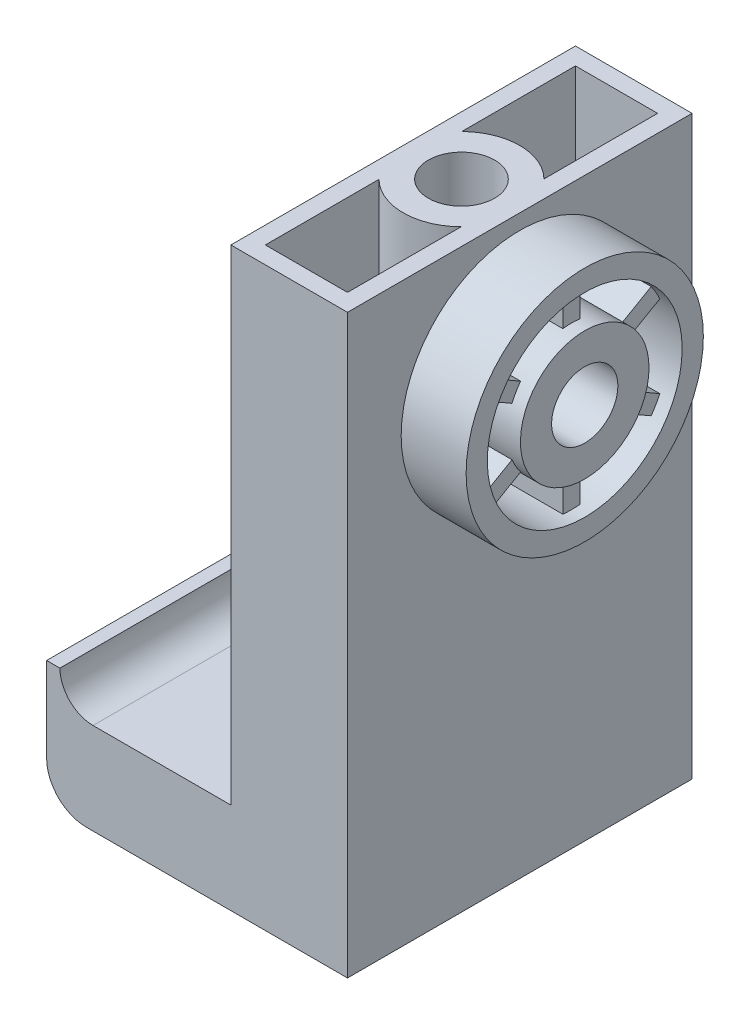
from build123d import *

# Parameters (mm, degrees)
BOSS_EXTRUDE1_DEPTH = 16.51
SKETCH2_R           = 11.3665
SKETCH2_R_2         = 3.175
BOSS_EXTRUDE2_DEPTH = 6.223
SKETCH3_W           = 1.27
SKETCH3_H           = 3.175
SKETCH4_R           = 3.175
CUT_EXTRUDE1_DEPTH  = 54.61


with BuildPart() as part:
    # Sketch1 → Boss-Extrude1 (new body, symmetric)
    with BuildSketch(Plane.XY):
        with BuildLine():
            Line((-28.829, 11.938), (-27.559, 11.938))
            ThreePointArc((-27.559, 11.938), (-26.62906403, 9.69293597), (-24.384, 8.763))
            Line((-24.384, 8.763), (-11.176, 8.763))
            Line((-11.176, 8.763), (-11.176, 55.245))
            Line((-11.176, 55.245), (0, 55.245))
            Line((0, 55.245), (0, 0))
            Line((0, 0), (-25.019, 0))
            ThreePointArc((-25.019, 0), (-27.713076836, 1.115923164), (-28.829, 3.81))
            Line((-28.829, 3.81), (-28.829, 11.938))
        make_face()
    extrude(amount=BOSS_EXTRUDE1_DEPTH, both=True)

    # Sketch2 → Boss-Extrude2 (add)
    with BuildSketch(Plane(origin=(0, 0, 0), x_dir=(0, 0, -1), z_dir=(1, 0, 0))):
        with Locations((0, 42.418)):
            Circle(SKETCH2_R)
        with Locations((0, 42.418)):
            Circle(SKETCH2_R_2, mode=Mode.SUBTRACT)
        with BuildLine():
            Line((-0.8255, 48.521932339), (-0.8255, 51.715926651))
            ThreePointArc((-0.8255, 51.715926651), (-4.66725, 50.501914132), (-7.639490682, 47.781867296))
            Line((-7.639490682, 47.781867296), (-4.873410469, 46.18487014))
            ThreePointArc((-4.873410469, 46.18487014), (-3.07975, 47.752283475), (-0.8255, 48.521932339))
        make_face(mode=Mode.SUBTRACT)
        with BuildLine():
            Line((0.8255, 48.521932339), (0.8255, 51.715926651))
            ThreePointArc((0.8255, 51.715926651), (4.66725, 50.501914132), (7.639490682, 47.781867296))
            Line((7.639490682, 47.781867296), (4.873410469, 46.18487014))
            ThreePointArc((4.873410469, 46.18487014), (3.07975, 47.752283475), (0.8255, 48.521932339))
        make_face(mode=Mode.SUBTRACT)
        with BuildLine():
            Line((5.698910469, 44.755062199), (8.464990682, 46.352059354))
            ThreePointArc((8.464990682, 46.352059354), (9.3345, 42.418), (8.464990682, 38.483940646))
            Line((8.464990682, 38.483940646), (5.698910469, 40.080937801))
            ThreePointArc((5.698910469, 40.080937801), (6.1595, 42.418), (5.698910469, 44.755062199))
        make_face(mode=Mode.SUBTRACT)
        with BuildLine():
            Line((4.873410469, 38.65112986), (7.639490682, 37.054132704))
            ThreePointArc((7.639490682, 37.054132704), (4.66725, 34.334085868), (0.8255, 33.120073349))
            Line((0.8255, 33.120073349), (0.8255, 36.314067661))
            ThreePointArc((0.8255, 36.314067661), (3.07975, 37.083716525), (4.873410469, 38.65112986))
        make_face(mode=Mode.SUBTRACT)
        with BuildLine():
            Line((-0.8255, 36.314067661), (-0.8255, 33.120073349))
            ThreePointArc((-0.8255, 33.120073349), (-4.66725, 34.334085868), (-7.639490682, 37.054132704))
            Line((-7.639490682, 37.054132704), (-4.873410469, 38.65112986))
            ThreePointArc((-4.873410469, 38.65112986), (-3.07975, 37.083716525), (-0.8255, 36.314067661))
        make_face(mode=Mode.SUBTRACT)
        with BuildLine():
            Line((-5.698910469, 40.080937801), (-8.464990682, 38.483940646))
            ThreePointArc((-8.464990682, 38.483940646), (-9.3345, 42.418), (-8.464990682, 46.352059354))
            Line((-8.464990682, 46.352059354), (-5.698910469, 44.755062199))
            ThreePointArc((-5.698910469, 44.755062199), (-6.1595, 42.418), (-5.698910469, 40.080937801))
        make_face(mode=Mode.SUBTRACT)
    extrude(amount=BOSS_EXTRUDE2_DEPTH)

    # Sketch3 → Cut-Revolve1 (revolve, cut)
    with BuildSketch(Plane.XY):
        with Locations((5.588, 50.165)):
            Rectangle(SKETCH3_W, SKETCH3_H)
    revolve(axis=Axis((6.223, 42.418, 0), (-1, 0, 0)), mode=Mode.SUBTRACT)

    # Sketch4 → Cut-Extrude1 (cut)
    with BuildSketch(Plane(origin=(0, 55.245, 0), x_dir=(1, 0, 0), z_dir=(0, 1, 0))):
        with BuildLine():
            Line((-1.651, 3.965573729), (-1.651, 14.859))
            Line((-1.651, 14.859), (-9.525, 14.859))
            Line((-9.525, 14.859), (-9.525, 3.965573729))
            ThreePointArc((-9.525, 3.965573729), (-5.588, 5.588), (-1.651, 3.965573729))
        make_face()
        with BuildLine():
            Line((-1.651, -14.859), (-1.651, -3.965573729))
            ThreePointArc((-1.651, -3.965573729), (-5.588, -5.588), (-9.525, -3.965573729))
            Line((-9.525, -3.965573729), (-9.525, -14.859))
            Line((-9.525, -14.859), (-1.651, -14.859))
        make_face()
        with Locations((-5.588, 0)):
            Circle(SKETCH4_R)
    extrude(amount=-CUT_EXTRUDE1_DEPTH, mode=Mode.SUBTRACT)


solid = part.part
